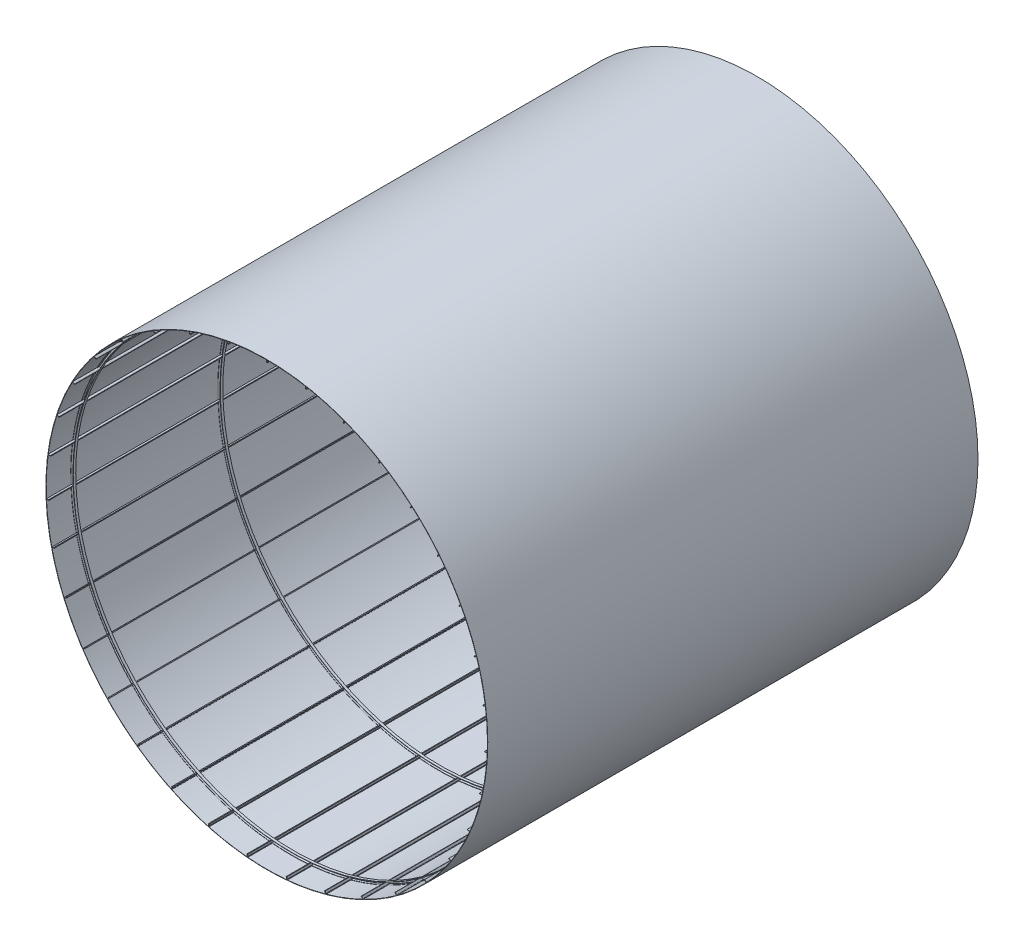
from build123d import *

# Parameters (mm, degrees)
SKETCH1_R           = 901.5
SKETCH1_R_2         = 900
BOSS_EXTRUDE1_DEPTH = 2000
SKETCH2_W           = 1.5
SKETCH2_H           = 7
SKETCH2_W_2         = 3
SKETCH2_H_2         = 1.5
BOSS_EXTRUDE2_DEPTH = 2000
CIRPATTERN1_COUNT   = 35
SKETCH3_W           = 8.4
SKETCH3_H           = 1
LPATTERN1_COUNT     = 4
LPATTERN1_PITCH     = 600


with BuildPart() as part:
    # Sketch1 → Boss-Extrude1 (new body)
    with BuildSketch(Plane.XY):
        Circle(SKETCH1_R)
        Circle(SKETCH1_R_2, mode=Mode.SUBTRACT)
    extrude(amount=BOSS_EXTRUDE1_DEPTH)

    # Sketch2 → Boss-Extrude2 (add)
    with BuildSketch(Plane.XY):
        with Locations((-0.75, 895)):
            Rectangle(SKETCH2_W, SKETCH2_H)
        Polygon((1.5, 891.5), (0, 891.5), (-1.5, 891.5), (-1.5, 890), (1.5, 890), align=None)
        with Locations((-1.5, 899.25)):
            Rectangle(SKETCH2_W_2, SKETCH2_H_2)
    boss_extrude2 = extrude(amount=BOSS_EXTRUDE2_DEPTH)

    # CirPattern1: Boss-Extrude2 ×35 about axis
    cirpattern1_axis = Axis((0, 0, 0), (0, 0, 1))
    for i in range(1, CIRPATTERN1_COUNT):
        add(boss_extrude2.rotate(cirpattern1_axis, i * 360 / CIRPATTERN1_COUNT))

    # Sketch3 → Revolve2 (revolve)
    with BuildSketch(Plane(origin=(0, 0, 0), x_dir=(1, 0, 0), z_dir=(0, 1, 0))):
        Polygon((899, -100.175039437), (900, -100.175039437), (900, -89.975039437), (899, -89.975039437), (899, -90.975039437), align=None)
        with Locations((894.8, -90.475039437)):
            Rectangle(SKETCH3_W, SKETCH3_H)
        Polygon((890.6, -100.175039437), (890.6, -90.975039437), (890.6, -89.975039437), (889.6, -89.975039437), (889.6, -100.175039437), align=None)
    revolve2 = revolve(axis=Axis((0, 0, 0), (0, 0, 1)))

    # LPattern1: Revolve2 ×4
    with Locations(*[(0, 0, i * LPATTERN1_PITCH) for i in range(1, LPATTERN1_COUNT)]):
        add(revolve2)


solid = part.part
